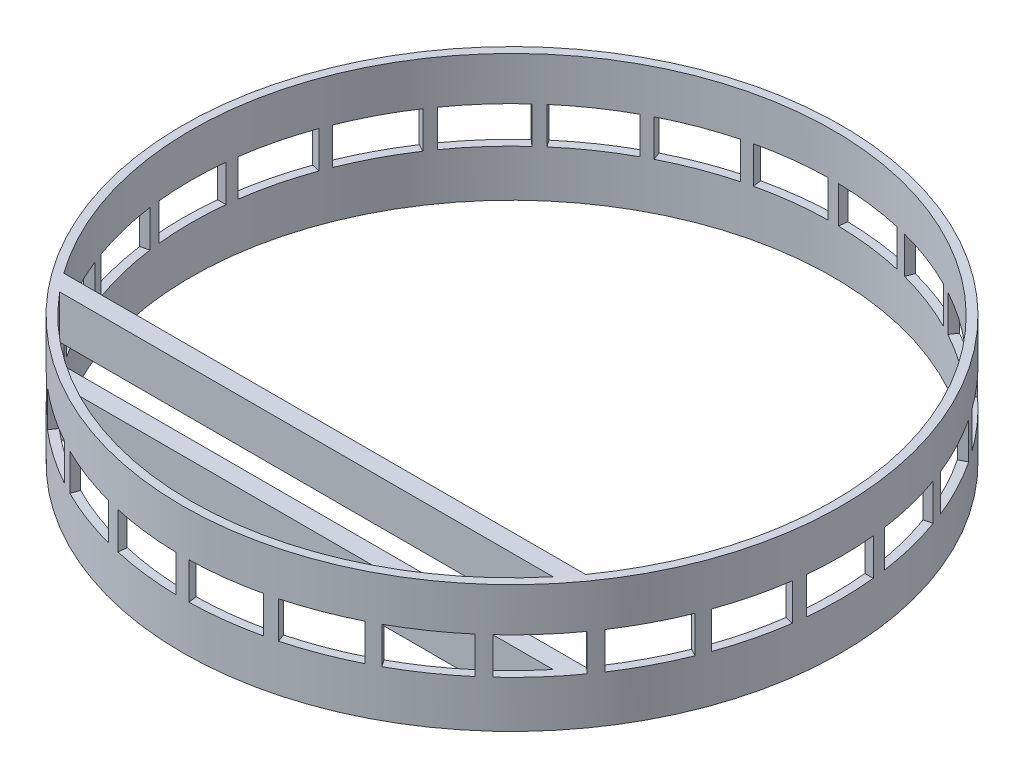
from build123d import *

# Parameters (mm, degrees)
BOSS_EXTRUDE1_DEPTH = 38
SKETCH2_W           = 20
SKETCH2_H           = 11
CUT_EXTRUDE1_DEPTH  = 145.390096613
CIRPATTERN1_COUNT   = 26


with BuildPart() as part:
    # Sketch1 → Boss-Extrude1 (new body)
    with BuildSketch(Plane(origin=(0, 0, 0), x_dir=(1, 0, 0), z_dir=(0, 1, 0))):
        with BuildLine():
            ThreePointArc((76.973491541, -61.46), (79.050100656, -58.765054125), (81.032400927, -56))
            Line((81.032400927, -56), (77.974354758, -56))
            ThreePointArc((77.974354758, -56), (75.90994771, -58.76801714), (73.747328087, -61.46))
            Line((73.747328087, -61.46), (76.973491541, -61.46))
        make_face()
        with BuildLine():
            ThreePointArc((73.747328087, -61.46), (75.90994771, -58.76801714), (77.974354758, -56))
            Line((77.974354758, -56), (-77.974354758, -56))
            ThreePointArc((-77.974354758, -56), (-75.90994771, -58.76801714), (-73.747328087, -61.46))
            Line((-73.747328087, -61.46), (73.747328087, -61.46))
        make_face()
        with BuildLine():
            ThreePointArc((-73.747328087, -61.46), (-75.90994771, -58.76801714), (-77.974354758, -56))
            Line((-77.974354758, -56), (-81.032400927, -56))
            ThreePointArc((-81.032400927, -56), (-79.050100656, -58.765054125), (-76.973491541, -61.46))
            Line((-76.973491541, -61.46), (-73.747328087, -61.46))
        make_face()
        with BuildLine():
            Line((77.974354758, -56), (81.032400927, -56))
            ThreePointArc((81.032400927, -56), (94.031753922, -29.330517458), (98.5, 0))
            ThreePointArc((98.5, 0), (-29.330517458, 94.031753922), (-81.032400927, -56))
            Line((-81.032400927, -56), (-77.974354758, -56))
            ThreePointArc((-77.974354758, -56), (-29.414808713, 91.382542252), (96, 0))
            ThreePointArc((96, 0), (91.382542252, -29.414808713), (77.974354758, -56))
        make_face()
        with BuildLine():
            ThreePointArc((-76.973491541, -61.46), (0, -98.5), (76.973491541, -61.46))
            Line((76.973491541, -61.46), (73.747328087, -61.46))
            ThreePointArc((73.747328087, -61.46), (0, -96), (-73.747328087, -61.46))
            Line((-73.747328087, -61.46), (-76.973491541, -61.46))
        make_face()
    extrude(amount=BOSS_EXTRUDE1_DEPTH)

    # Sketch2 → Cut-Extrude1 (cut, through all)
    with BuildSketch(Plane(origin=(0, 0, 0), x_dir=(0, 0, -1), z_dir=(1, 0, 0))):
        with Locations((0, 19.5)):
            Rectangle(SKETCH2_W, SKETCH2_H)
    cut_extrude1 = extrude(amount=-CUT_EXTRUDE1_DEPTH, mode=Mode.SUBTRACT)

    # CirPattern1: Cut-Extrude1 ×26 about axis
    cirpattern1_axis = Axis((0, 0, 0), (0, 1, 0))
    for i in range(1, CIRPATTERN1_COUNT):
        add(cut_extrude1.rotate(cirpattern1_axis, i * 360 / CIRPATTERN1_COUNT), mode=Mode.SUBTRACT)


solid = part.part
